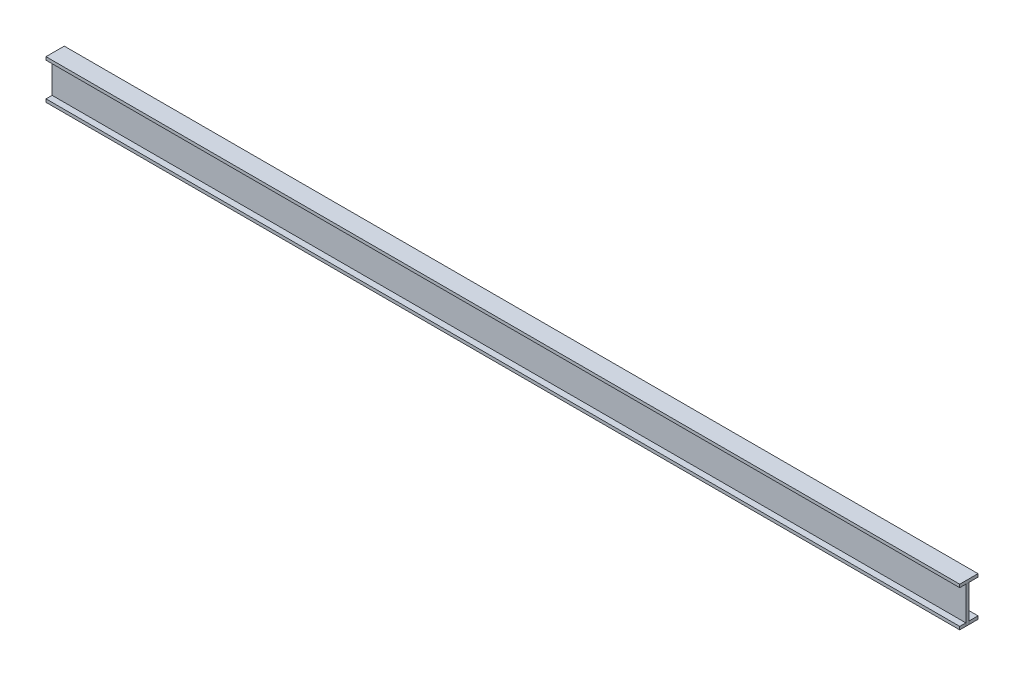
from build123d import *

# Parameters (mm, degrees)
SKETCH_1_W        = 60
SKETCH_1_H        = 10
EXTRUDE_1_DEPTH   = 3000
SKETCH_1_W_2      = 10
SKETCH_1_H_2      = 120
EXTRUDE_1_2_DEPTH = 3000
EXTRUDE_1_3_DEPTH = 3000


with BuildPart() as part:
    # Эскиз1 → Вытянуть-Тонкостенный1 (new body)
    with BuildSketch(Plane(origin=(0, 0, 0), x_dir=(0, 0, -1), z_dir=(1, 0, 0))):
        with Locations((0, 5)):
            Rectangle(SKETCH_1_W, SKETCH_1_H)
    extrude(amount=EXTRUDE_1_DEPTH)


with BuildPart() as body_2:
    # Эскиз1 → Extrude 1 2 (new body)
    with BuildSketch(Plane(origin=(0, 0, 0), x_dir=(0, 0, -1), z_dir=(1, 0, 0))):
        with Locations((-5, 60)):
            Rectangle(SKETCH_1_W_2, SKETCH_1_H_2)
    extrude(amount=EXTRUDE_1_2_DEPTH)


with BuildPart() as body_3:
    # Эскиз1 → Extrude 1 3 (new body)
    with BuildSketch(Plane(origin=(0, 0, 0), x_dir=(0, 0, -1), z_dir=(1, 0, 0))):
        with Locations((0, 125)):
            Rectangle(SKETCH_1_W, SKETCH_1_H)
    extrude(amount=EXTRUDE_1_3_DEPTH)


solid = Compound([part.part, body_2.part, body_3.part])
